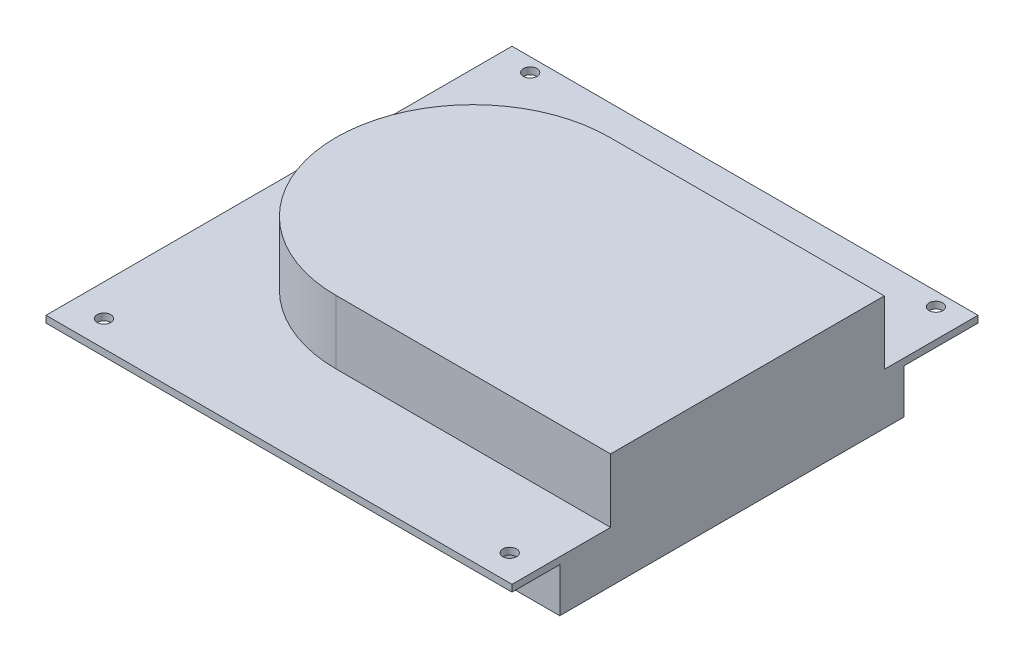
from build123d import *

# Parameters (mm, degrees)
SKETCH1_W           = 104.14
SKETCH1_H           = 104.14
SKETCH1_R           = 1.524
BOSS_EXTRUDE1_DEPTH = 1.524
BOSS_EXTRUDE2_DEPTH = 14.224
SKETCH3_W           = 18.136210303
SKETCH3_H           = 76.873137305
BOSS_EXTRUDE3_DEPTH = 9.906
SKETCH5_W           = 17.139817269
SKETCH5_H           = 51.595631098
BOSS_EXTRUDE4_DEPTH = 9.906


with BuildPart() as part:
    # Sketch1 → Boss-Extrude1 (new body)
    with BuildSketch(Plane(origin=(0, 0, 0), x_dir=(1, 0, 0), z_dir=(0, 1, 0))):
        with Locations((52.07, 52.07)):
            Rectangle(SKETCH1_W, SKETCH1_H)
        with Locations((7.112, 101.092)):
            Circle(SKETCH1_R, mode=Mode.SUBTRACT)
        with Locations((97.79, 101.092)):
            Circle(SKETCH1_R, mode=Mode.SUBTRACT)
        with Locations((7.112, 5.842)):
            Circle(SKETCH1_R, mode=Mode.SUBTRACT)
        with Locations((97.79, 5.842)):
            Circle(SKETCH1_R, mode=Mode.SUBTRACT)
    extrude(amount=BOSS_EXTRUDE1_DEPTH)

    # Sketch2 → Boss-Extrude2 (add)
    with BuildSketch(Plane(origin=(0, 1.524, 0), x_dir=(1, 0, 0), z_dir=(0, 1, 0))):
        with BuildLine():
            Line((104.14, 22.024034198), (104.14, 83.197819697))
            Line((104.14, 83.197819697), (42.798644119, 83.197819697))
            ThreePointArc((42.798644119, 83.197819697), (64.426843398, 74.239126226), (73.385536869, 52.610926948))
            ThreePointArc((73.385536869, 52.610926948), (64.426843398, 30.982727669), (42.798644119, 22.024034198))
            Line((42.798644119, 22.024034198), (104.14, 22.024034198))
        make_face()
        with BuildLine():
            ThreePointArc((73.385536869, 52.610926948), (64.426843398, 74.239126226), (42.798644119, 83.197819697))
            Line((42.798644119, 83.197819697), (42.798644119, 22.024034198))
            ThreePointArc((42.798644119, 22.024034198), (64.426843398, 30.982727669), (73.385536869, 52.610926948))
        make_face()
        with BuildLine():
            Line((42.798644119, 22.024034198), (42.798644119, 83.197819697))
            ThreePointArc((42.798644119, 83.197819697), (12.211751369, 52.610926948), (42.798644119, 22.024034198))
        make_face()
    extrude(amount=BOSS_EXTRUDE2_DEPTH)

    # Sketch3 → Boss-Extrude3 (add)
    with BuildSketch(Plane.XZ):
        with Locations((95.071894848, -49.113594912)):
            Rectangle(SKETCH3_W, SKETCH3_H)
    extrude(amount=BOSS_EXTRUDE3_DEPTH)

    # Sketch5 → Boss-Extrude4 (add)
    with BuildSketch(Plane.XZ):
        with Locations((8.569908635, -48.177785321)):
            Rectangle(SKETCH5_W, SKETCH5_H)
    extrude(amount=BOSS_EXTRUDE4_DEPTH)


solid = part.part
